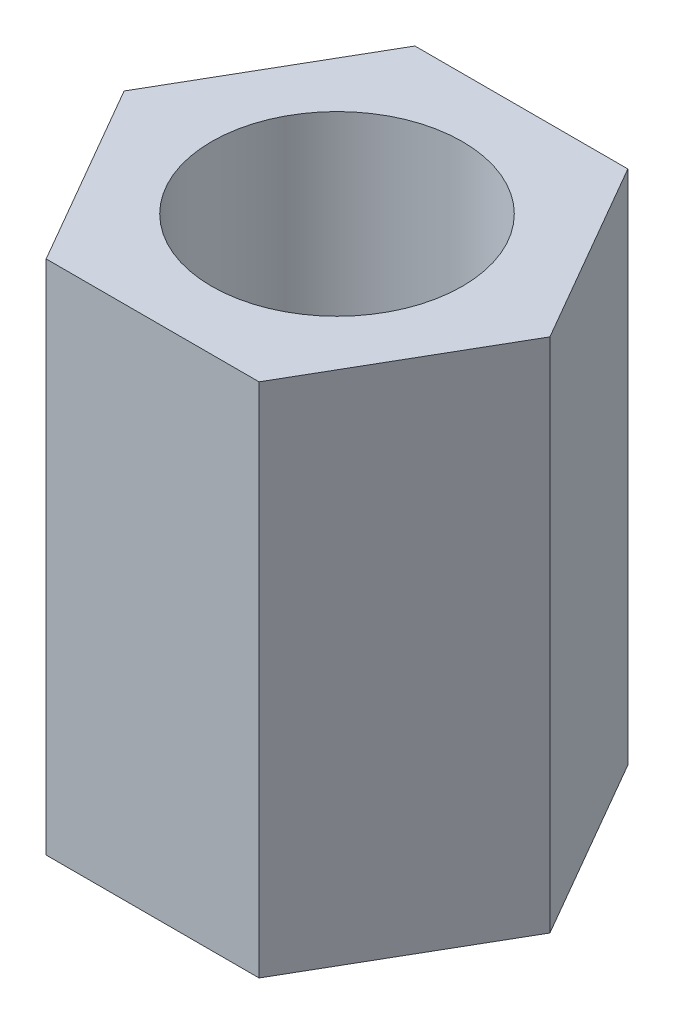
from build123d import *

# Parameters (mm, degrees)
SKETCH1_R           = 1.7
BOSS_EXTRUDE1_DEPTH = 3.5


with BuildPart() as part:
    # Sketch1 → Boss-Extrude1 (new body, symmetric)
    with BuildSketch(Plane(origin=(0, 0, 0), x_dir=(1, 0, 0), z_dir=(0, 1, 0))):
        Polygon((-2.886751346, 0), (-1.443375673, -2.5), (1.443375673, -2.5), (2.886751346, 0), (1.443375673, 2.5), (-1.443375673, 2.5), align=None)
        Circle(SKETCH1_R, mode=Mode.SUBTRACT)
    extrude(amount=BOSS_EXTRUDE1_DEPTH, both=True)


solid = part.part
